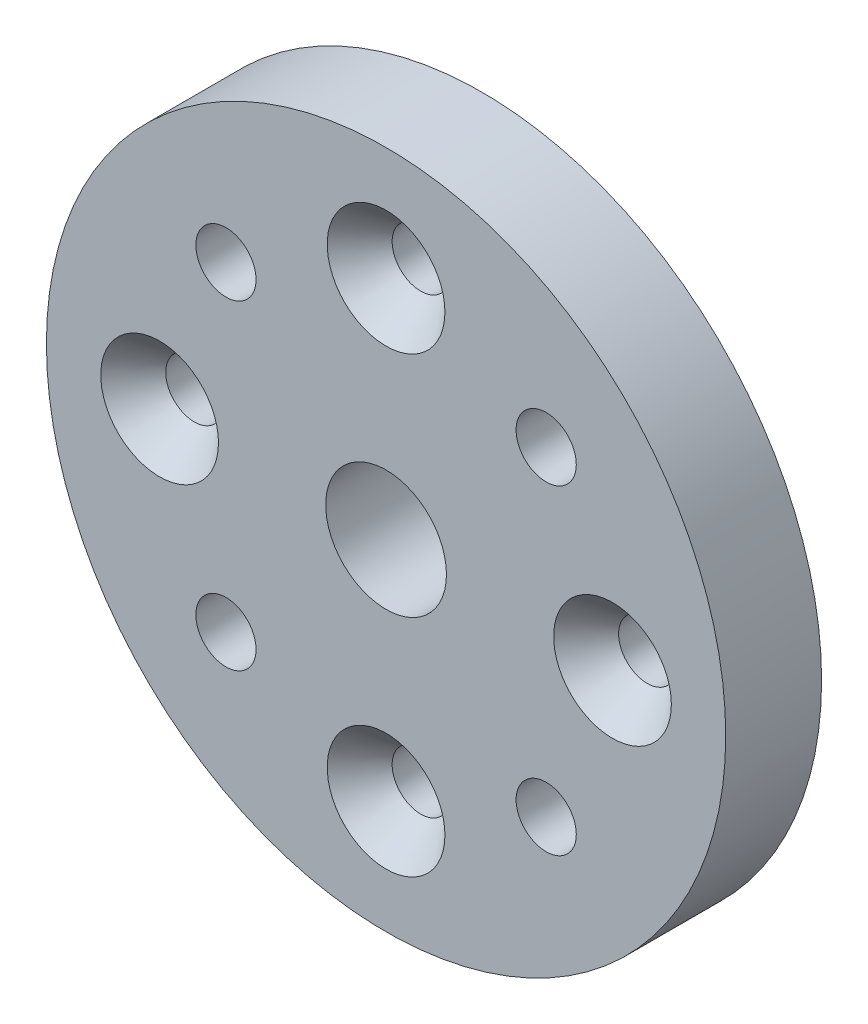
from build123d import *

# Parameters (mm, degrees)
SKETCH1_R             = 22.5
SKETCH1_R_2           = 4
SKETCH1_R_3           = 1.89865
SKETCH1_R_4           = 1.9939
BOSS_EXTRUDE1_DEPTH   = 6.35
CHAMFER1_SIZE         = 2.301024407
CHAMFER1_SIZE2        = 2.00025
CHAMFER1_PART_2_SIZE  = 2.301024407
CHAMFER1_PART_2_SIZE2 = 2.00025
CHAMFER1_PART_3_SIZE  = 2.301024407
CHAMFER1_PART_3_SIZE2 = 2.00025
CHAMFER1_PART_4_SIZE  = 2.301024407
CHAMFER1_PART_4_SIZE2 = 2.00025


with BuildPart() as part:
    # Sketch1 → Boss-Extrude1 (new body)
    with BuildSketch(Plane.XY):
        Circle(SKETCH1_R)
        Circle(SKETCH1_R_2, mode=Mode.SUBTRACT)
        with Locations((0, 15)):
            Circle(SKETCH1_R_3, mode=Mode.SUBTRACT)
        with Locations((10.606601718, 10.606601718)):
            Circle(SKETCH1_R_4, mode=Mode.SUBTRACT)
        with Locations((15, 0)):
            Circle(SKETCH1_R_3, mode=Mode.SUBTRACT)
        with Locations((10.606601718, -10.606601718)):
            Circle(SKETCH1_R_4, mode=Mode.SUBTRACT)
        with Locations((0, -15)):
            Circle(SKETCH1_R_3, mode=Mode.SUBTRACT)
        with Locations((-10.606601718, -10.606601718)):
            Circle(SKETCH1_R_4, mode=Mode.SUBTRACT)
        with Locations((-15, 0)):
            Circle(SKETCH1_R_3, mode=Mode.SUBTRACT)
        with Locations((-10.606601718, 10.606601718)):
            Circle(SKETCH1_R_4, mode=Mode.SUBTRACT)
    extrude(amount=BOSS_EXTRUDE1_DEPTH)

    # Chamfer1
    chamfer1_edges = [part.edges().sort_by_distance(p)[0] for p in [
        (13.10135, 0, 6.35),
    ]]
    chamfer1_side = [part.faces().sort_by_distance(p)[0] for p in [
        (13.10135, 0, 3.175),
    ]]
    chamfer(chamfer1_edges, length=CHAMFER1_SIZE, length2=CHAMFER1_SIZE2, reference=chamfer1_side[0])

    # Chamfer1 part 2
    chamfer1_part_2_edges = [part.edges().sort_by_distance(p)[0] for p in [
        (-1.89865, -15, 6.35),
    ]]
    chamfer1_part_2_side = [part.faces().sort_by_distance(p)[0] for p in [
        (-1.89865, -15, 3.175),
    ]]
    chamfer(chamfer1_part_2_edges, length=CHAMFER1_PART_2_SIZE, length2=CHAMFER1_PART_2_SIZE2, reference=chamfer1_part_2_side[0])

    # Chamfer1 part 3
    chamfer1_part_3_edges = [part.edges().sort_by_distance(p)[0] for p in [
        (-16.89865, 0, 6.35),
    ]]
    chamfer1_part_3_side = [part.faces().sort_by_distance(p)[0] for p in [
        (-16.89865, 0, 3.175),
    ]]
    chamfer(chamfer1_part_3_edges, length=CHAMFER1_PART_3_SIZE, length2=CHAMFER1_PART_3_SIZE2, reference=chamfer1_part_3_side[0])

    # Chamfer1 part 4
    chamfer1_part_4_edges = [part.edges().sort_by_distance(p)[0] for p in [
        (-1.89865, 15, 6.35),
    ]]
    chamfer1_part_4_side = [part.faces().sort_by_distance(p)[0] for p in [
        (-1.89865, 15, 3.175),
    ]]
    chamfer(chamfer1_part_4_edges, length=CHAMFER1_PART_4_SIZE, length2=CHAMFER1_PART_4_SIZE2, reference=chamfer1_part_4_side[0])


solid = part.part
